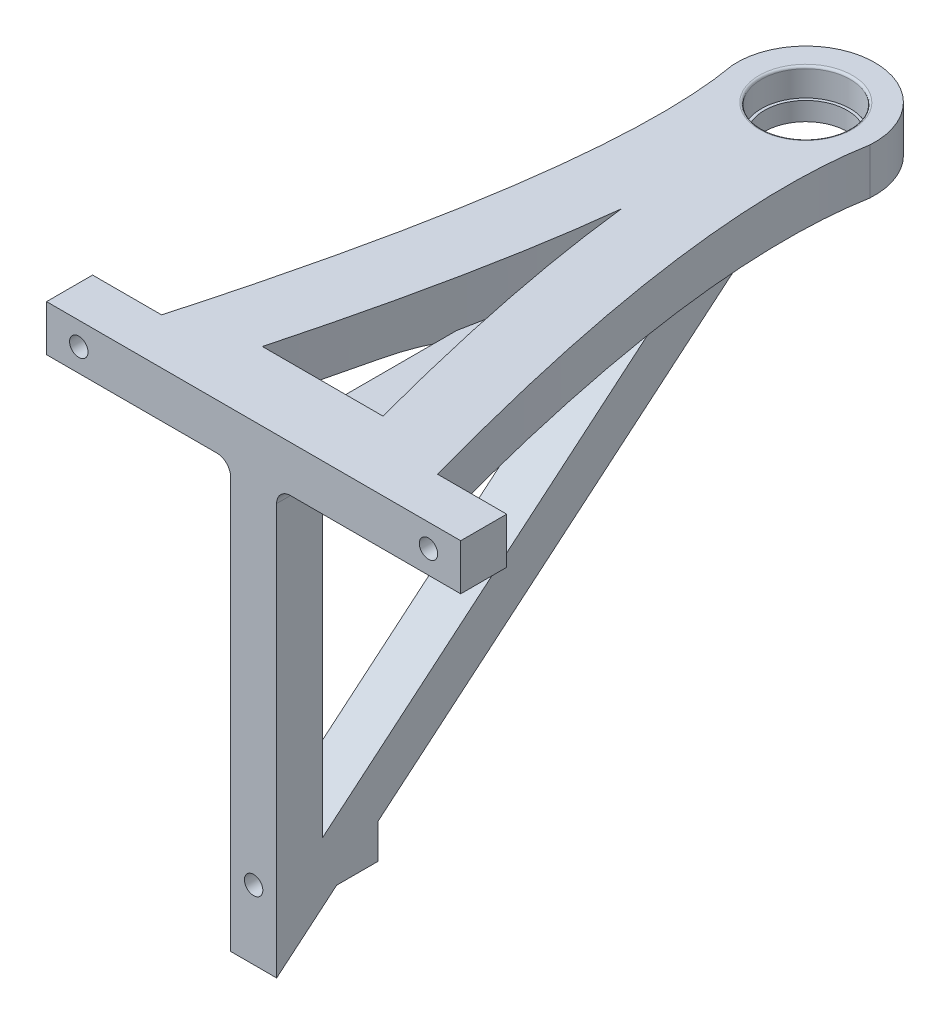
from build123d import *

# Parameters (mm, degrees)
EXTRUDE_1_DEPTH      = 10
SKETCH_2_R           = 9.65
CUT_EXTRUDE_1_DEPTH  = 6
SKETCH_3_R           = 9
CUT_EXTRUDE_2_DEPTH  = 108.971611223
SKETCH_4_R           = 2
CUT_EXTRUDE_3_DEPTH  = 134.22912608
FILLET_2_R           = 0.5
EXTRUDE_3_DEPTH      = 5
EXTRUDE_3_DEPTH_BACK = 5
FILLET_3_R           = 3
FILLET_4_R           = 3
FILLET_5_R           = 3
FILLET_6_R           = 3
SKETCH_8_W           = 10
SKETCH_8_H           = 8.119253015
EXTRUDE_5_DEPTH      = 22
SKETCH_7_R           = 2
CUT_EXTRUDE_4_DEPTH  = 170.615645405


with BuildPart() as part:
    # Эскиз1 → Бобышка-Вытянуть1 (new body)
    with BuildSketch(Plane(origin=(0, 0, 0), x_dir=(1, 0, 0), z_dir=(0, 1, 0))):
        with BuildLine():
            Line((-45, -37.036390428), (45, -37.036390428))
            Line((45, -37.036390428), (45, -27.036390428))
            Line((45, -27.036390428), (30, -27.036390428))
            add(Edge.make_bspline(
                [(30, -27.036390428), (8.982189831, 48.482679734), (14.96841635, 81.990721102)],
                knots=[0, 0, 0, 0.673052388, 0.673052388, 0.673052388], degree=2))
            ThreePointArc((14.96841635, 81.990721102), (0, 97.963609572), (-14.96841635, 81.990721102))
            add(Edge.make_bspline(
                [(-30, -27.036390428), (-8.982189831, 48.482679734), (-14.96841635, 81.990721102)],
                knots=[0, 0, 0, 0.673052388, 0.673052388, 0.673052388], degree=2))
            Line((-30, -27.036390428), (-45, -27.036390428))
            Line((-45, -27.036390428), (-45, -37.036390428))
        make_face()
        with BuildLine():
            Line((-13.093802095, -22.036390428), (13.093802095, -22.036390428))
            add(Edge.make_bspline(
                [(0, 42.892969081), (0.131197091, 41.727442037), (0.406798356, 39.416984329), (1.035729687, 34.652549779), (1.955297059, 28.529668977), (3.27425138, 20.876880517), (4.806507266, 12.923420182), (6.551708297, 4.662649881), (8.508532438, -3.905250597), (10.317434597, -11.311565536), (11.866516335, -17.379327452), (12.683259953, -20.491905055), (13.093802095, -22.036390428)],
                knots=[0.040117253, 0.040117253, 0.040117253, 0.040117253, 0.061247944, 0.082378635, 0.124640016, 0.166901397, 0.209162778, 0.251424159, 0.29368554, 0.335946921, 0.357077612, 0.378208302, 0.378208302, 0.378208302, 0.378208302], degree=3))
            add(Edge.make_bspline(
                [(-13.093802095, -22.036390428), (-12.683259953, -20.491905055), (-11.866516335, -17.379327452), (-10.317434597, -11.311565536), (-8.508532438, -3.905250597), (-6.551708297, 4.662649881), (-4.806507266, 12.923420182), (-3.27425138, 20.876880517), (-1.955297059, 28.529668977), (-1.035729687, 34.652549779), (-0.406798356, 39.416984329), (-0.131197091, 41.727442037), (0, 42.892969081)],
                knots=[0.040117253, 0.040117253, 0.040117253, 0.040117253, 0.061247944, 0.082378635, 0.124640016, 0.166901397, 0.209162778, 0.251424159, 0.29368554, 0.335946921, 0.357077612, 0.378208302, 0.378208302, 0.378208302, 0.378208302], degree=3))
        make_face(mode=Mode.SUBTRACT)
    extrude(amount=EXTRUDE_1_DEPTH)

    # Эскиз2 → Вырез-Вытянуть1 (cut)
    with BuildSketch(Plane(origin=(0, 10, 0), x_dir=(1, 0, 0), z_dir=(0, 1, 0))):
        with Locations(Location((0, 82.963609572, 0), (0, 0, 270))):
            Circle(SKETCH_2_R)
    extrude(amount=-CUT_EXTRUDE_1_DEPTH, mode=Mode.SUBTRACT)

    # Эскиз3 → Вырез-Вытянуть2 (cut, through all)
    with BuildSketch(Plane(origin=(0, 4, 0), x_dir=(1, 0, 0), z_dir=(0, 1, 0))):
        with Locations(Location((0, 82.963609572, 0), (0, 0, 270))):
            Circle(SKETCH_3_R)
    extrude(amount=-CUT_EXTRUDE_2_DEPTH, mode=Mode.SUBTRACT)

    # Эскиз4 → Вырез-Вытянуть3 (cut, through all)
    with BuildSketch(Plane(origin=(0, 0, 27.036390428), x_dir=(-1, 0, 0), z_dir=(0, 0, -1))):
        with Locations((38, 5)):
            Circle(SKETCH_4_R)
        with Locations((-38, 5)):
            Circle(SKETCH_4_R)
    extrude(amount=-CUT_EXTRUDE_3_DEPTH, mode=Mode.SUBTRACT)

    # Скругление2
    fillet_2_edges = [part.edges().sort_by_distance(p)[0] for p in [
        (0, 10, -92.613609572),
    ]]
    fillet(fillet_2_edges, radius=FILLET_2_R)

    # Эскиз6 → Бобышка-Вытянуть3 (add, two sides)
    with BuildSketch(Plane(origin=(0, 0, 0), x_dir=(0, 0, -1), z_dir=(1, 0, 0))) as extrude_3_sk:
        Polygon((72.963609572, 0), (-37.036390428, 0), (-37.036390428, -92.300959429), align=None)
        Polygon((45.488835377, -10), (-27.036390428, -10), (-27.036390428, -70.855890224), align=None, mode=Mode.SUBTRACT)
    extrude(amount=EXTRUDE_3_DEPTH)
    extrude(extrude_3_sk.sketch, amount=-EXTRUDE_3_DEPTH_BACK)

    # Скругление3
    fillet_3_edges = [part.edges().sort_by_distance(p)[0] for p in [
        (5, 0, 29.536390428),
    ]]
    fillet(fillet_3_edges, radius=FILLET_3_R)

    # Скругление4
    fillet_4_edges = [part.edges().sort_by_distance(p)[0] for p in [
        (5, 0, -42.52878468),
    ]]
    fillet(fillet_4_edges, radius=FILLET_4_R)

    # Скругление5
    fillet_5_edges = [part.edges().sort_by_distance(p)[0] for p in [
        (-5, 0, -42.52878468),
    ]]
    fillet(fillet_5_edges, radius=FILLET_5_R)

    # Скругление6
    fillet_6_edges = [part.edges().sort_by_distance(p)[0] for p in [
        (-5, 0, 29.536390428),
    ]]
    fillet(fillet_6_edges, radius=FILLET_6_R)

    # Эскиз8 → Бобышка-Вытянуть5 (add)
    with BuildSketch(Plane.XY.offset(37.036390428)):
        with Locations((0, -77.30095943)):
            Rectangle(SKETCH_8_W, SKETCH_8_H)
    extrude(amount=-EXTRUDE_5_DEPTH)

    # Эскиз7 → Вырез-Вытянуть4 (cut, through all)
    with BuildSketch(Plane.XY.offset(37.036390428)):
        with Locations((0, -77.300959429)):
            Circle(SKETCH_7_R)
    extrude(amount=-CUT_EXTRUDE_4_DEPTH, mode=Mode.SUBTRACT)


solid = part.part
